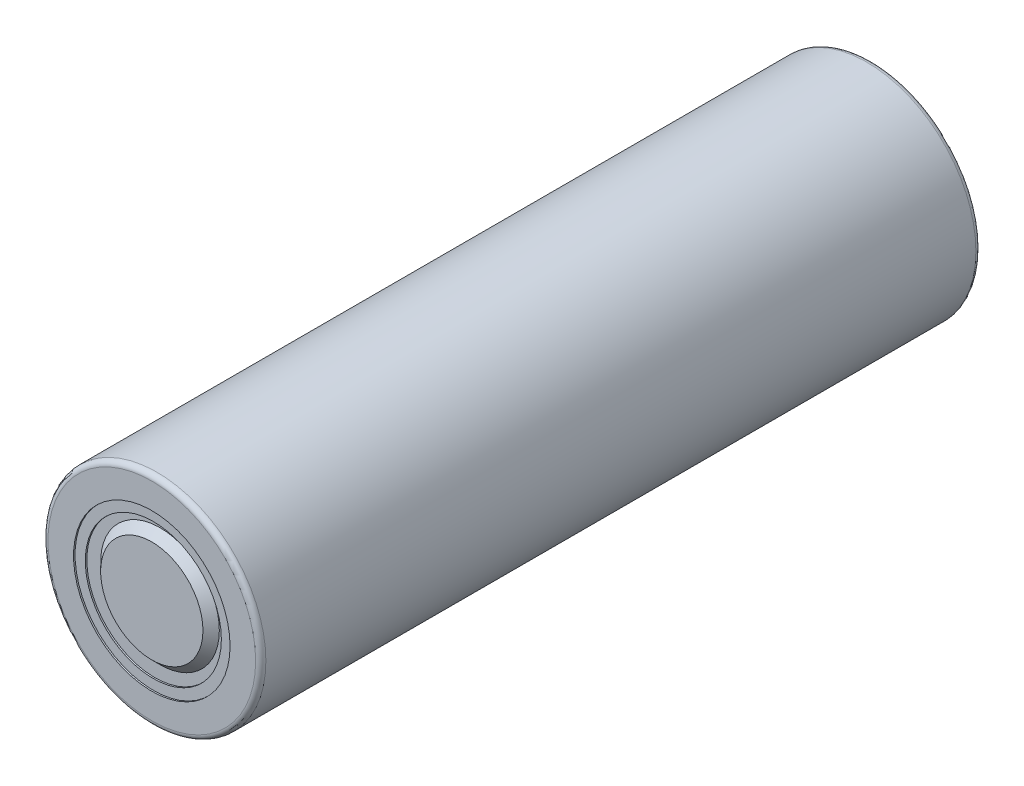
from build123d import *

# Parameters (mm, degrees)
SKETCH1_R           = 10.65
BOSS_EXTRUDE1_DEPTH = 70.4
SKETCH2_R           = 8.65
CUT_EXTRUDE1_DEPTH  = 0.2
FILLET1_R           = 0.5


with BuildPart() as part:
    # Sketch1 → Boss-Extrude1 (new body)
    with BuildSketch(Plane.XY):
        Circle(SKETCH1_R)
    extrude(amount=BOSS_EXTRUDE1_DEPTH)

    # Sketch2 → Cut-Extrude1 (cut)
    with BuildSketch(Plane.XY):
        Circle(SKETCH2_R)
    extrude(amount=CUT_EXTRUDE1_DEPTH, mode=Mode.SUBTRACT)

    # Sketch3 → Cut-Revolve1 (revolve, cut)
    with BuildSketch(Plane(origin=(0, 0, 0), x_dir=(1, 0, 0), z_dir=(0, 1, 0))):
        Polygon((-9.149999999, -70.1), (-9.149999999, -69.600000001), (-5.799999999, -69.600000001), (-5, -70.4), (-7.650000002, -70.4), (-7.650000002, -70.25), (-6.649999999, -70.25), (-6.649999999, -70.1), align=None)
    revolve(axis=Axis((0, 0, 70.4), (0, 0, -1)), mode=Mode.SUBTRACT)

    # Fillet1
    fillet1_edges = [part.edges().sort_by_distance(p)[0] for p in [
        (-10.65, 0, 0),
        (-10.65, 0, 70.4),
    ]]
    fillet(fillet1_edges, radius=FILLET1_R)


solid = part.part
